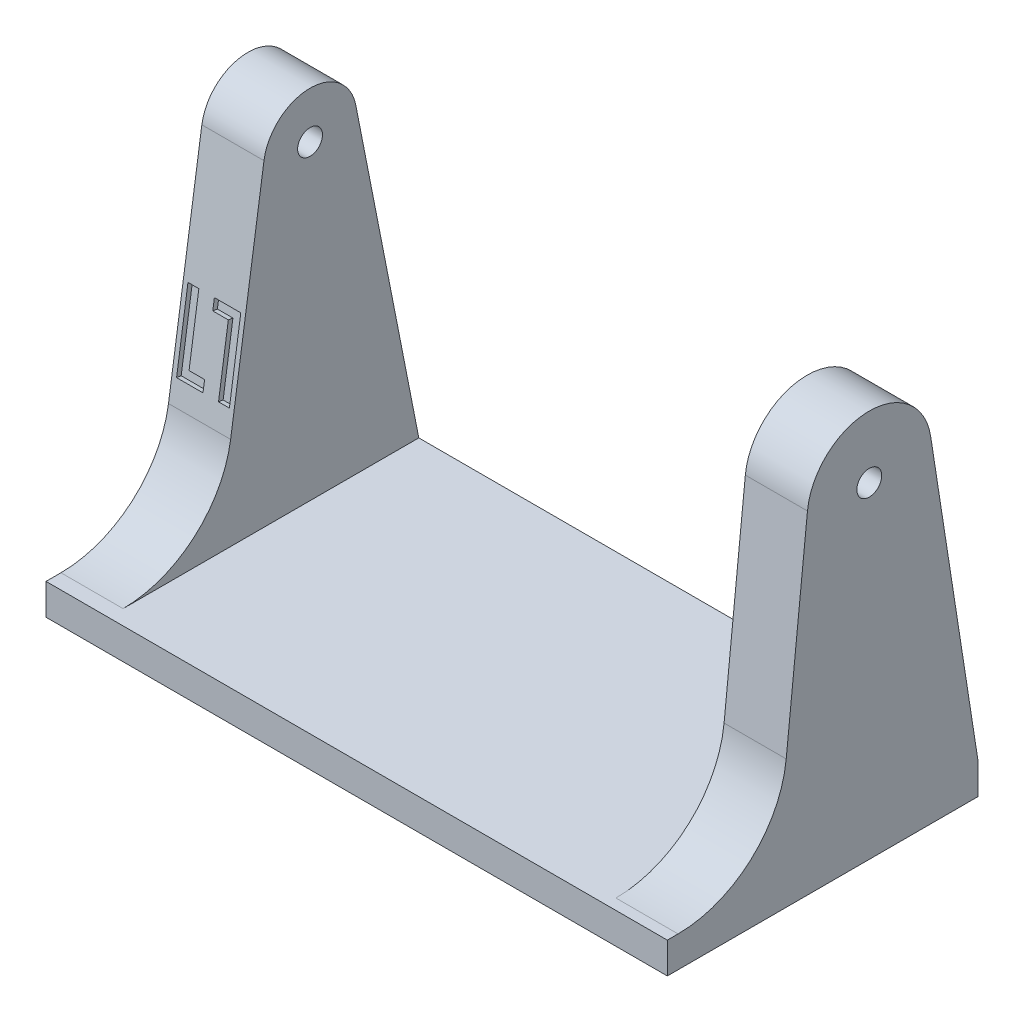
from build123d import *

# Parameters (mm, degrees)
CROQUIS1_W              = 40
CROQUIS1_H              = 20
SALIENTE_EXTRUIR1_DEPTH = 2
CROQUIS3_R              = 0.8
SALIENTE_EXTRUIR2_DEPTH = 4
CROQUIS4_R              = 2.5
CROQUIS4_R_2            = 1
CORTAR_EXTRUIR1_DEPTH   = 0.2
CROQUIS6_R              = 0.8
SALIENTE_EXTRUIR3_DEPTH = 4
CROQUIS10_R             = 2.4
CORTAR_EXTRUIR4_DEPTH   = 2
CORTAR_EXTRUIR5_DEPTH   = 0.3


with BuildPart() as part:
    # Croquis1 → Saliente-Extruir1 (new body)
    with BuildSketch(Plane(origin=(0, 0, 0), x_dir=(1, 0, 0), z_dir=(0, 1, 0))):
        Rectangle(CROQUIS1_W, CROQUIS1_H)
    extrude(amount=SALIENTE_EXTRUIR1_DEPTH)

    # Croquis3 → Saliente-Extruir2 (add)
    with BuildSketch(Plane(origin=(20, 0, 0), x_dir=(0, 0, -1), z_dir=(1, 0, 0))):
        with BuildLine():
            Line((-2.346611166, 8.275044598), (-0.978490727, 21.414260229))
            ThreePointArc((-0.978490727, 21.414260229), (2.899239812, 24.998730722), (6.952577869, 21.614107636))
            Line((6.952577869, 21.614107636), (10, 2))
            Line((10, 2), (-9.308969938, 2))
            ThreePointArc((-9.308969938, 2), (-4.622536743, 3.8002554), (-2.346611166, 8.275044598))
        make_face()
        with Locations((3, 21)):
            Circle(CROQUIS3_R, mode=Mode.SUBTRACT)
    extrude(amount=-SALIENTE_EXTRUIR2_DEPTH)

    # Croquis4 → Cortar-Extruir1 (cut)
    with BuildSketch(Plane.XZ):
        with Locations((7, -5)):
            Circle(CROQUIS4_R)
        with Locations((7, -5)):
            Circle(CROQUIS4_R_2, mode=Mode.SUBTRACT)
        with BuildLine():
            Line((0.5, 8), (0.5, 6))
            ThreePointArc((0.5, 6), (0, 5.5), (-0.5, 6))
            Line((-0.5, 6), (-0.5, 8))
            ThreePointArc((-0.5, 8), (0, 8.5), (0.5, 8))
        make_face()
        with BuildLine():
            Line((2, 8), (2, 6))
            ThreePointArc((2, 6), (2.5, 5.5), (3, 6))
            Line((3, 6), (3, 8))
            ThreePointArc((3, 8), (2.5, 8.5), (2, 8))
        make_face()
        with BuildLine():
            Line((4.5, 8), (4.5, 6))
            ThreePointArc((4.5, 6), (5, 5.5), (5.5, 6))
            Line((5.5, 6), (5.5, 8))
            ThreePointArc((5.5, 8), (5, 8.5), (4.5, 8))
        make_face()
        with BuildLine():
            Line((7, 8), (7, 6))
            ThreePointArc((7, 6), (7.5, 5.5), (8, 6))
            Line((8, 6), (8, 8))
            ThreePointArc((8, 8), (7.5, 8.5), (7, 8))
        make_face()
        with BuildLine():
            Line((9.5, 8), (9.5, 6))
            ThreePointArc((9.5, 6), (10, 5.5), (10.5, 6))
            Line((10.5, 6), (10.5, 8))
            ThreePointArc((10.5, 8), (10, 8.5), (9.5, 8))
        make_face()
        with BuildLine():
            Line((12, 8), (12, 6))
            ThreePointArc((12, 6), (12.5, 5.5), (13, 6))
            Line((13, 6), (13, 8))
            ThreePointArc((13, 8), (12.5, 8.5), (12, 8))
        make_face()
    cortar_extruir1 = extrude(amount=-CORTAR_EXTRUIR1_DEPTH, mode=Mode.SUBTRACT)

    # Simetría2: Cortar-Extruir1 across plane
    add(cortar_extruir1.mirror(Plane(origin=(0, 0, 0), x_dir=(0, 0, 1), z_dir=(1, 0, 0))), mode=Mode.SUBTRACT)

    # Croquis6 → Saliente-Extruir3 (add)
    with BuildSketch(Plane.ZY.offset(20)):
        with BuildLine():
            Line((-10, 2), (-5.943364405, 22.580177542))
            ThreePointArc((-5.943364405, 22.580177542), (-2.929004345, 24.999159819), (-0.032480048, 22.440255986))
            Line((-0.032480048, 22.440255986), (2.113895498, 7.972736033))
            ThreePointArc((2.113895498, 7.972736033), (4.465956479, 3.699488338), (9.03810872, 2))
            Line((9.03810872, 2), (-10, 2))
        make_face()
        with Locations((-3, 22)):
            Circle(CROQUIS6_R, mode=Mode.SUBTRACT)
    extrude(amount=-SALIENTE_EXTRUIR3_DEPTH)

    # Croquis10 → Cortar-Extruir4 (cut)
    with BuildSketch(Plane.ZY.offset(-16)):
        with Locations((-3, 21)):
            Circle(CROQUIS10_R)
    extrude(amount=-CORTAR_EXTRUIR4_DEPTH, mode=Mode.SUBTRACT)

    # Croquis11 → Cortar-Extruir5 (cut)
    with BuildSketch(Plane(origin=(0, 0.47856177, 3.225717872), x_dir=(1, 0, 0), z_dir=(0, 0.146751995, 0.989173317))):
        Polygon((-16.3, 9.076199369), (-17, 9.076199369), (-17, 13.376199369), (-18, 13.376199369), (-18, 14.076199369), (-16.3, 14.076199369), align=None)
        Polygon((-19.7, 9.076199369), (-19.7, 14.076199369), (-19, 14.076199369), (-19, 9.776199369), (-18, 9.776199369), (-18, 9.076199369), align=None)
    extrude(amount=-CORTAR_EXTRUIR5_DEPTH, mode=Mode.SUBTRACT)


solid = part.part
